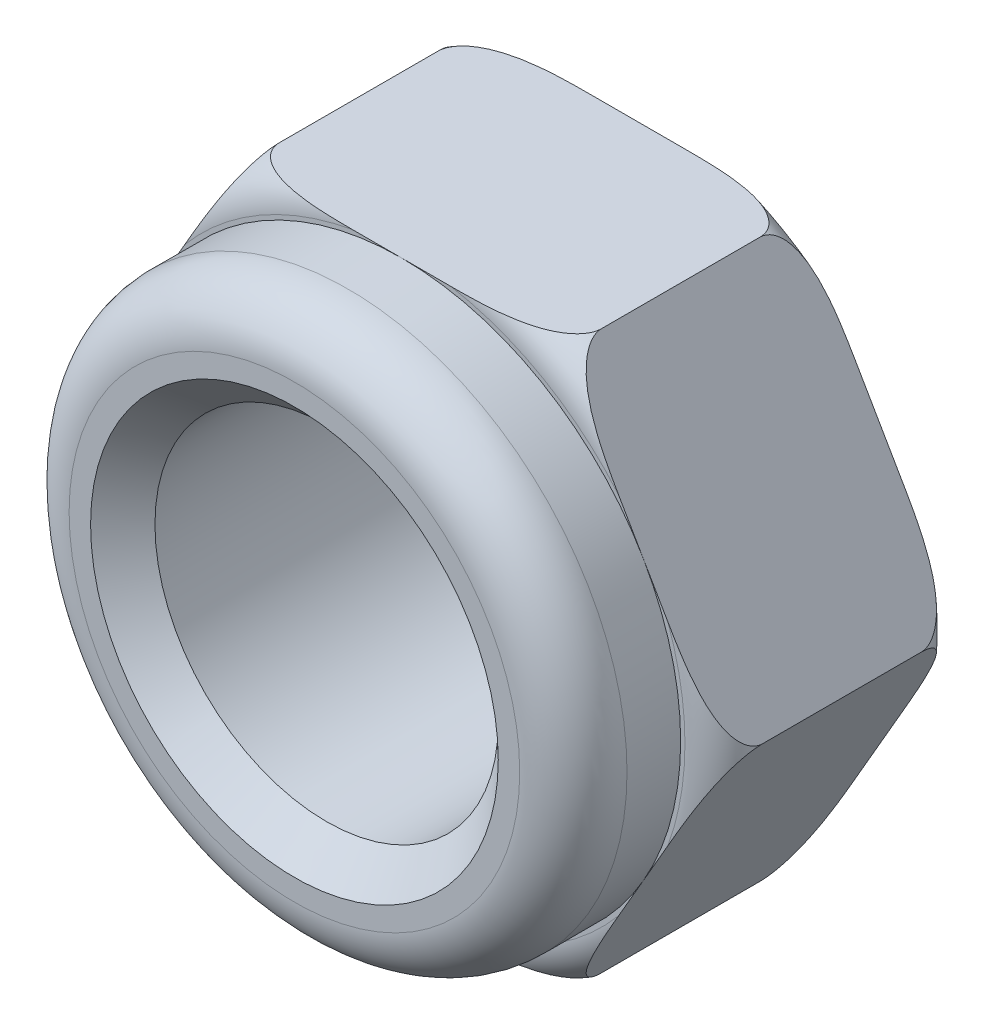
from build123d import *

# Parameters (mm, degrees)
SZKIC1_R                    = 4
DODANIE_WYCI_GNI_CIE1_DEPTH = 5.5
SZKIC2_R                    = 6.5
SZKIC2_R_2                  = 4
DODANIE_WYCI_GNI_CIE2_DEPTH = 8
SFAZOWANIE1_SIZE            = 0.75


with BuildPart() as part:
    # Szkic1 → Dodanie-wyciągnięcie1 (new body)
    with BuildSketch(Plane.XY):
        Polygon((-7.505553499, 0), (-3.75277675, -6.5), (3.75277675, -6.5), (7.505553499, 0), (3.75277675, 6.5), (-3.75277675, 6.5), align=None)
        Circle(SZKIC1_R, mode=Mode.SUBTRACT)
    extrude(amount=DODANIE_WYCI_GNI_CIE1_DEPTH)

    # Szkic2 → Dodanie-wyciągnięcie2 (add)
    with BuildSketch(Plane.XY):
        Circle(SZKIC2_R)
        Circle(SZKIC2_R_2, mode=Mode.SUBTRACT)
    extrude(amount=DODANIE_WYCI_GNI_CIE2_DEPTH)

    # Sfazowanie1
    sfazowanie1_edges = [part.edges().sort_by_distance(p)[0] for p in [
        (-4, 0, 0),
        (-4, 0, 8),
    ]]
    chamfer(sfazowanie1_edges, length=SFAZOWANIE1_SIZE)

    # Szkic3 → Wycięcie-obrót1 (revolve, cut)
    with BuildSketch(Plane(origin=(0, 0, 0), x_dir=(1, 0, 0), z_dir=(0, 1, 0))):
        with BuildLine():
            Line((-7.505553499, 0), (-7.505553499, -0.905553499))
            ThreePointArc((-7.505553499, -0.905553499), (-7.24032302, -0.265230479), (-6.6, 0))
            Line((-6.6, 0), (-7.505553499, 0))
        make_face()
        with BuildLine():
            ThreePointArc((-6.6, -5.5), (-7.24032302, -5.234769521), (-7.505553499, -4.594446501))
            Line((-7.505553499, -4.594446501), (-7.505553499, -5.5))
            Line((-7.505553499, -5.5), (-6.6, -5.5))
        make_face()
        with BuildLine():
            Line((-6.5, -8), (-5.25, -8))
            ThreePointArc((-5.25, -8), (-6.133883476, -7.633883476), (-6.5, -6.75))
            Line((-6.5, -6.75), (-6.5, -8))
        make_face()
    revolve(axis=Axis((0, 0, -1.701574894), (0, 0, 1)), mode=Mode.SUBTRACT)


solid = part.part
